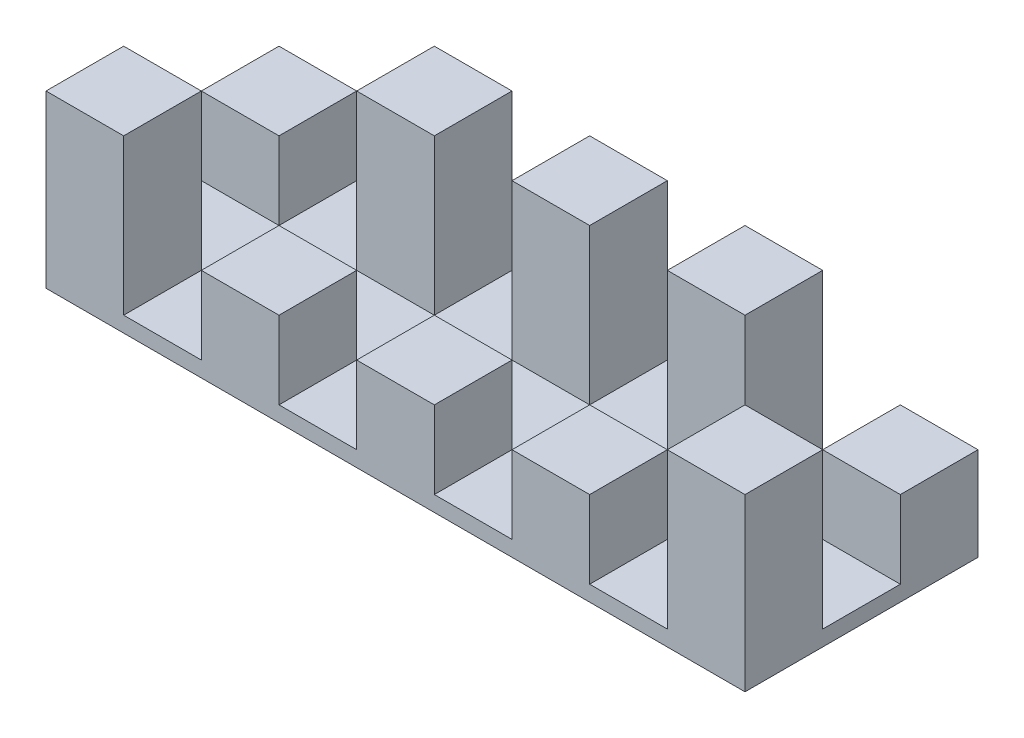
from build123d import *

# Parameters (mm, degrees)
SKETCH2_W           = 50
SKETCH2_H           = 50
BOSS_EXTRUDE4_DEPTH = 10
SKETCH5_W           = 50
SKETCH5_H           = 50
BOSS_EXTRUDE5_DEPTH = 50
SKETCH6_W           = 50
SKETCH6_H           = 50
BOSS_EXTRUDE6_DEPTH = 100
SKETCH7_W           = 50
SKETCH7_H           = 50
BOSS_EXTRUDE7_DEPTH = 100
SKETCH8_W           = 50
SKETCH8_H           = 50
BOSS_EXTRUDE8_DEPTH = 50


with BuildPart() as part:
    # Sketch2 → Boss-Extrude4 (new body)
    with BuildSketch(Plane(origin=(0, 0, 0), x_dir=(1, 0, 0), z_dir=(0, 1, 0))):
        Polygon((-125, 75), (-175, 75), (-175, 25), (-225, 25), (-225, -25), (-175, -25), (-175, -75), (-125, -75), (-125, -25), (-75, -25), (-75, -75), (-25.420673077, -75), (-25.420673077, -25), (24.579326923, -25), (24.579326923, -75), (75, -75), (75, -25), (125, -25), (125, -75), (175, -75), (175, -25), (225, -25), (225, 25), (175, 25), (175, 75), (125, 75), (125, 25), (75, 25), (75, 75), (24.579326923, 75), (24.579326923, 25), (-25.420673077, 25), (-25.420673077, 75), (-75, 75), (-75, 25), (-125, 25), align=None)
        with Locations((-200, -50)):
            Rectangle(SKETCH2_W, SKETCH2_H)
        with Locations((-100, -50)):
            Rectangle(SKETCH2_W, SKETCH2_H)
        with Locations((-200, 50)):
            Rectangle(SKETCH2_W, SKETCH2_H)
        with Locations((-100, 50)):
            Rectangle(SKETCH2_W, SKETCH2_H)
        with Locations((-0.420673077, -50)):
            Rectangle(SKETCH2_W, SKETCH2_H)
        with Locations((-0.420673077, 50)):
            Rectangle(SKETCH2_W, SKETCH2_H)
        with Locations((100, 50)):
            Rectangle(SKETCH2_W, SKETCH2_H)
        with Locations((100, -50)):
            Rectangle(SKETCH2_W, SKETCH2_H)
        with Locations((200, -50)):
            Rectangle(SKETCH2_W, SKETCH2_H)
        with Locations((200, 50)):
            Rectangle(SKETCH2_W, SKETCH2_H)
    extrude(amount=BOSS_EXTRUDE4_DEPTH)

    # Sketch5 → Boss-Extrude5 (add)
    with BuildSketch(Plane(origin=(0, 10, 0), x_dir=(1, 0, 0), z_dir=(0, 1, 0))):
        with Locations((-200, 50)):
            Rectangle(SKETCH5_W, SKETCH5_H)
        with Locations((200, 50)):
            Rectangle(SKETCH5_W, SKETCH5_H)
    extrude(amount=BOSS_EXTRUDE5_DEPTH)

    # Sketch6 → Boss-Extrude6 (add)
    with BuildSketch(Plane(origin=(0, 10, 0), x_dir=(1, 0, 0), z_dir=(0, 1, 0))):
        with Locations((-200, -50)):
            Rectangle(SKETCH6_W, SKETCH6_H)
        with Locations((200, -50)):
            Rectangle(SKETCH6_W, SKETCH6_H)
    extrude(amount=BOSS_EXTRUDE6_DEPTH)

    # Sketch7 → Boss-Extrude7 (add)
    with BuildSketch(Plane(origin=(0, 10, 0), x_dir=(1, 0, 0), z_dir=(0, 1, 0))):
        with Locations((-100, 50)):
            Rectangle(SKETCH7_W, SKETCH7_H)
        with Locations((0, 50)):
            Rectangle(SKETCH7_W, SKETCH7_H)
        with Locations((100, 50)):
            Rectangle(SKETCH7_W, SKETCH7_H)
    extrude(amount=BOSS_EXTRUDE7_DEPTH)

    # Sketch8 → Boss-Extrude8 (add)
    with BuildSketch(Plane(origin=(0, 10, 0), x_dir=(1, 0, 0), z_dir=(0, 1, 0))):
        with Locations((-100, -50)):
            Rectangle(SKETCH8_W, SKETCH8_H)
        with Locations((0, -50)):
            Rectangle(SKETCH8_W, SKETCH8_H)
        with Locations((100, -50)):
            Rectangle(SKETCH8_W, SKETCH8_H)
    extrude(amount=BOSS_EXTRUDE8_DEPTH)


solid = part.part
